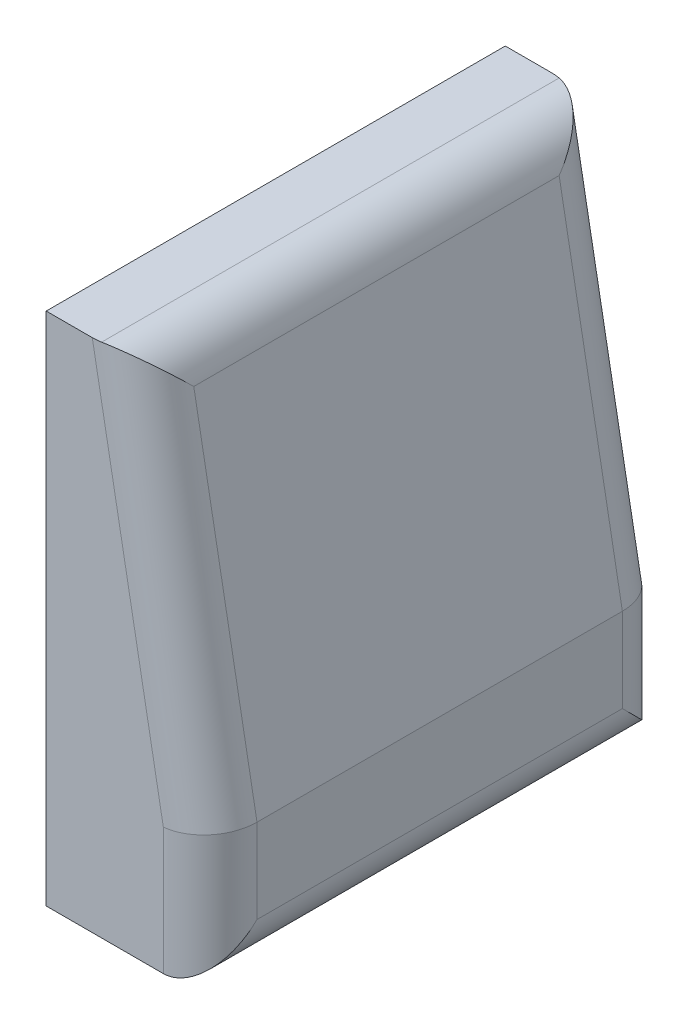
from build123d import *

# Parameters (mm, degrees)
BOSS_EXTRUDE1_DEPTH = 490
FILLET1_R           = 100


with BuildPart() as part:
    # Sketch1 → Boss-Extrude1 (new body, symmetric)
    with BuildSketch(Plane.XY):
        Polygon((0, 550), (0, -550), (350, -550), (350, -270), (200, 550), align=None)
    extrude(amount=BOSS_EXTRUDE1_DEPTH, both=True)

    # Fillet1
    fillet1_edges = [part.edges().sort_by_distance(p)[0] for p in [
        (350, -410, 490),
        (275, 140, 490),
        (275, 140, -490),
        (350, -410, -490),
        (200, 550, 0),
        (350, -550, 0),
    ]]
    fillet(fillet1_edges, radius=FILLET1_R)


solid = part.part
